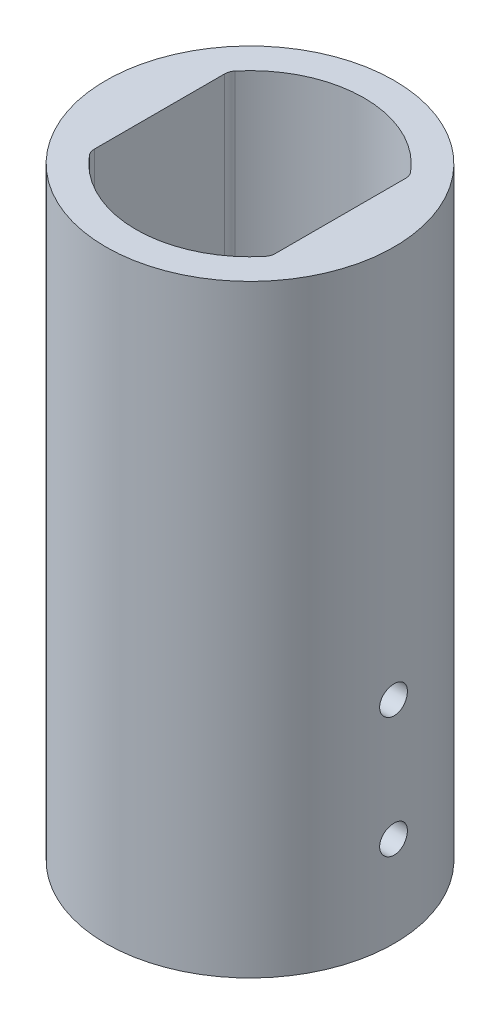
from build123d import *

# Parameters (mm, degrees)
SKETCH1_R               = 23.9
SKETCH1_R_2             = 18.9
BOSS_EXTRUDE1_DEPTH     = 100
SKETCH2_R               = 2.3
CUT_EXTRUDE1_DEPTH      = 24.9
CUT_EXTRUDE1_DEPTH_BACK = 24.9
FILLET1_R               = 2


with BuildPart() as part:
    # Sketch1 → Boss-Extrude1 (new body)
    with BuildSketch(Plane(origin=(0, 0, 0), x_dir=(1, 0, 0), z_dir=(0, 1, 0))):
        Circle(SKETCH1_R)
        Circle(SKETCH1_R_2, mode=Mode.SUBTRACT)
        with BuildLine():
            Line((-15, -11.498260738), (-15, 11.498260738))
            ThreePointArc((-15, 11.498260738), (-18.9, 0), (-15, -11.498260738))
        make_face()
        with BuildLine():
            ThreePointArc((18.9, 0), (17.898463621, 6.070831903), (15, 11.498260738))
            Line((15, 11.498260738), (15, -11.498260738))
            ThreePointArc((15, -11.498260738), (17.898463621, -6.070831903), (18.9, 0))
        make_face()
    extrude(amount=BOSS_EXTRUDE1_DEPTH)

    # Sketch2 → Cut-Extrude1 (cut, two sides)
    with BuildSketch(Plane(origin=(0, 0, 0), x_dir=(0, 0, -1), z_dir=(1, 0, 0))) as cut_extrude1_sk:
        with Locations((0, 15)):
            Circle(SKETCH2_R)
        with Locations((0, 35)):
            Circle(SKETCH2_R)
    extrude(amount=CUT_EXTRUDE1_DEPTH, mode=Mode.SUBTRACT)
    extrude(cut_extrude1_sk.sketch, amount=-CUT_EXTRUDE1_DEPTH_BACK, mode=Mode.SUBTRACT)

    # Fillet1
    fillet1_edges = [part.edges().sort_by_distance(p)[0] for p in [
        (15, 50, 11.498260738),
        (15, 50, -11.498260738),
        (-15, 50, -11.498260738),
        (-15, 50, 11.498260738),
    ]]
    fillet(fillet1_edges, radius=FILLET1_R)


solid = part.part
